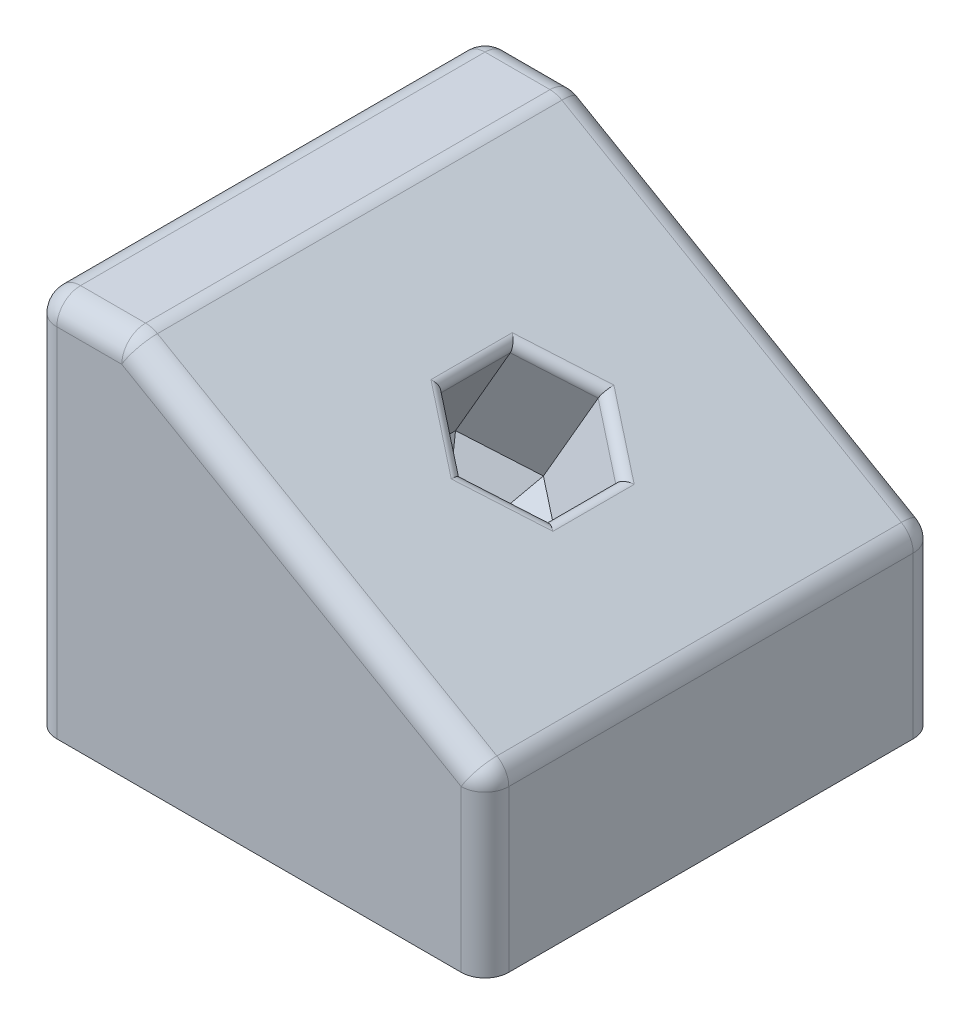
from build123d import *

# Parameters (mm, degrees)
SKETCH1_W           = 120.65
SKETCH1_H           = 120.65
BOSS_EXTRUDE1_DEPTH = 101.6
CUT_EXTRUDE1_DEPTH  = 120.65
CUT_EXTRUDE2_DEPTH  = 31.75
CUT_EXTRUDE3_DEPTH  = 6.35
CUT_EXTRUDE3_TAPER  = 45
FILLET1_R           = 6.35
FILLET2_R           = 2.54


with BuildPart() as part:
    # Sketch1 → Boss-Extrude1 (new body)
    with BuildSketch(Plane(origin=(0, 0, 0), x_dir=(1, 0, 0), z_dir=(0, 1, 0))):
        with Locations((36.473705191, 34.061776503)):
            Rectangle(SKETCH1_W, SKETCH1_H)
    extrude(amount=BOSS_EXTRUDE1_DEPTH)

    # Sketch3 → Cut-Extrude1 (cut)
    with BuildSketch(Plane.XY.offset(26.263223497)):
        Polygon((96.798705191, 101.6), (1.548705191, 101.6), (96.798705191, 46.60738686), align=None)
    extrude(amount=-CUT_EXTRUDE1_DEPTH, mode=Mode.SUBTRACT)

    # Sketch4 → Cut-Extrude2 (cut)
    with BuildSketch(Plane(origin=(44.38126681, 76.870609019, 0), x_dir=(0.866025404, -0.5, 0), z_dir=(0.5, 0.866025404, 0))):
        Polygon((5.533831179, 52.832588454), (-10.722168821, 43.447182479), (-10.722168821, 24.676370527), (5.533831179, 15.290964551), (21.789831179, 24.676370527), (21.789831179, 43.447182479), align=None)
    extrude(amount=-CUT_EXTRUDE2_DEPTH, mode=Mode.SUBTRACT)

    # Sketch5 → Cut-Extrude3 (cut)
    with BuildSketch(Plane(origin=(28.50626681, 49.374302449, 0), x_dir=(0.866025404, -0.5, 0), z_dir=(0.5, 0.866025404, 0))):
        Polygon((5.533831179, 15.290964551), (21.789831179, 24.676370527), (21.789831179, 43.447182479), (5.533831179, 52.832588454), (-10.722168821, 43.447182479), (-10.722168821, 24.676370527), align=None)
    extrude(amount=-CUT_EXTRUDE3_DEPTH, taper=CUT_EXTRUDE3_TAPER, mode=Mode.SUBTRACT)

    # Fillet1
    fillet1_edges = [part.edges().sort_by_distance(p)[0] for p in [
        (-11.151294809, 101.6, -94.386776503),
        (96.798705191, 23.30369343, -94.386776503),
        (96.798705191, 23.30369343, 26.263223497),
        (49.173705191, 74.10369343, -94.386776503),
        (96.798705191, 46.60738686, -34.061776503),
        (1.548705191, 101.6, -34.061776503),
        (49.173705191, 74.10369343, 26.263223497),
        (-23.851294809, 101.6, -34.061776503),
        (-11.151294809, 101.6, 26.263223497),
        (-23.851294809, 50.8, -94.386776503),
        (-23.851294809, 50.8, 26.263223497),
    ]]
    fillet(fillet1_edges, radius=FILLET1_R)

    # Fillet2
    fillet2_edges = [part.edges().sort_by_distance(p)[0] for p in [
        (56.212759673, 70.03969343, -48.139885467),
        (42.134650709, 78.16769343, -48.139885467),
        (35.095596227, 82.23169343, -34.061776503),
        (42.134650709, 78.16769343, -19.983667539),
        (56.212759673, 70.03969343, -19.983667539),
        (63.251814155, 65.97569343, -34.061776503),
    ]]
    fillet(fillet2_edges, radius=FILLET2_R)


solid = part.part
